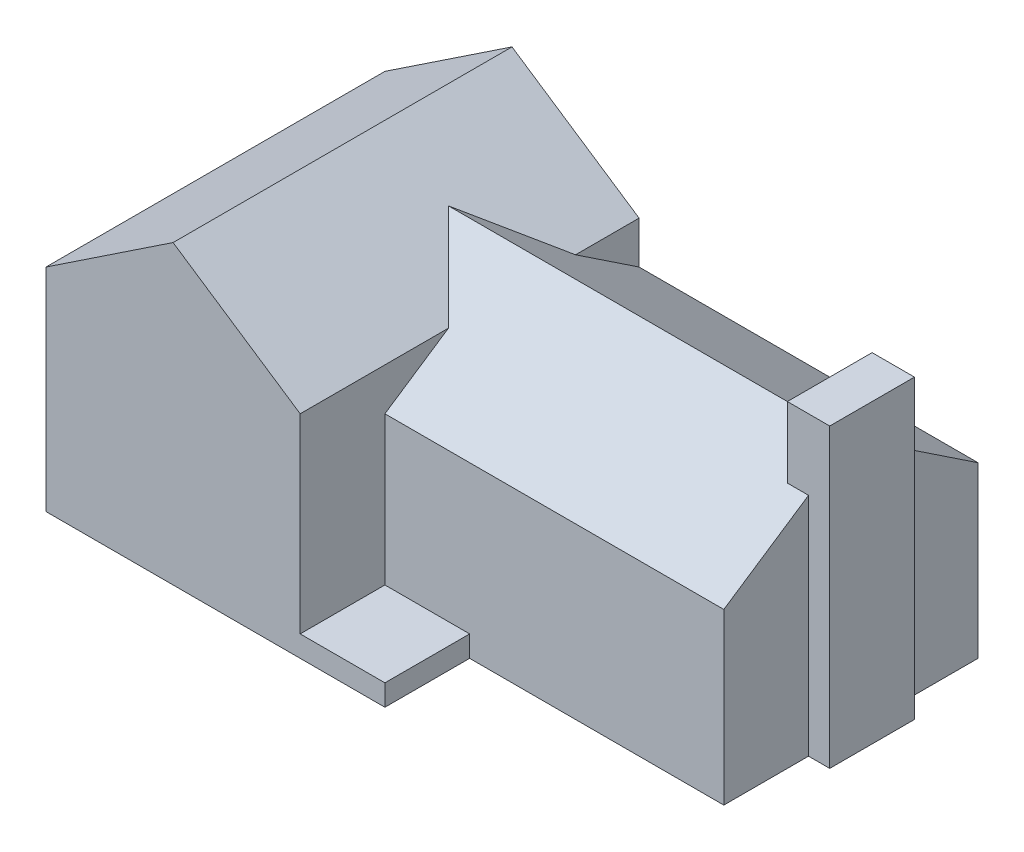
from build123d import *

# Parameters (mm, degrees)
SKETCH1_W                = 30
SKETCH1_H                = 40
BOSS_EXTRUDE1_DEPTH      = 25
BOSS_EXTRUDE2_DEPTH      = 40
SKETCH3_W                = 10
SKETCH3_H                = 40
BOSS_EXTRUDE3_DEPTH      = 2.5
SKETCH4_W                = 30
SKETCH4_H                = 20
BOSS_EXTRUDE4_DEPTH      = 40
BOSS_EXTRUDE5_DEPTH      = 55
SKETCH6_W                = 10
SKETCH6_H                = 35
BOSS_EXTRUDE7_DEPTH      = 2.5
BOSS_EXTRUDE7_DEPTH_BACK = 2.5


with BuildPart() as part:
    # Sketch1 → Boss-Extrude1 (new body)
    with BuildSketch(Plane(origin=(0, 0, 0), x_dir=(1, 0, 0), z_dir=(0, 1, 0))):
        with Locations((15, 20)):
            Rectangle(SKETCH1_W, SKETCH1_H)
    extrude(amount=BOSS_EXTRUDE1_DEPTH)

    # Sketch2 → Boss-Extrude2 (add)
    with BuildSketch(Plane.XY):
        Polygon((15, 25), (30, 25), (15, 35), (0, 25), align=None)
    extrude(amount=-BOSS_EXTRUDE2_DEPTH)

    # Sketch3 → Boss-Extrude3 (add)
    with BuildSketch(Plane(origin=(0, 0, 0), x_dir=(-1, 0, 0), z_dir=(0, -1, 0))):
        with Locations((-35, 20)):
            Rectangle(SKETCH3_W, SKETCH3_H)
    extrude(amount=-BOSS_EXTRUDE3_DEPTH)

    # Sketch4 → Boss-Extrude4 (add)
    with BuildSketch(Plane(origin=(30, 0, 0), x_dir=(0, 0, -1), z_dir=(1, 0, 0))):
        with Locations((25, 10)):
            Rectangle(SKETCH4_W, SKETCH4_H)
    extrude(amount=BOSS_EXTRUDE4_DEPTH)

    # Sketch5 → Boss-Extrude5 (add)
    with BuildSketch(Plane(origin=(70, 0, 0), x_dir=(0, 0, -1), z_dir=(1, 0, 0))):
        Polygon((25, 20), (10, 20), (25, 30), (40, 20), align=None)
    extrude(amount=-BOSS_EXTRUDE5_DEPTH)

    # Sketch6 → Boss-Extrude7 (add, two sides)
    with BuildSketch(Plane(origin=(70, 0, 0), x_dir=(0, 0, -1), z_dir=(1, 0, 0))) as boss_extrude7_sk:
        with Locations((25, 17.5)):
            Rectangle(SKETCH6_W, SKETCH6_H)
    extrude(amount=BOSS_EXTRUDE7_DEPTH)
    extrude(boss_extrude7_sk.sketch, amount=-BOSS_EXTRUDE7_DEPTH_BACK)


solid = part.part
